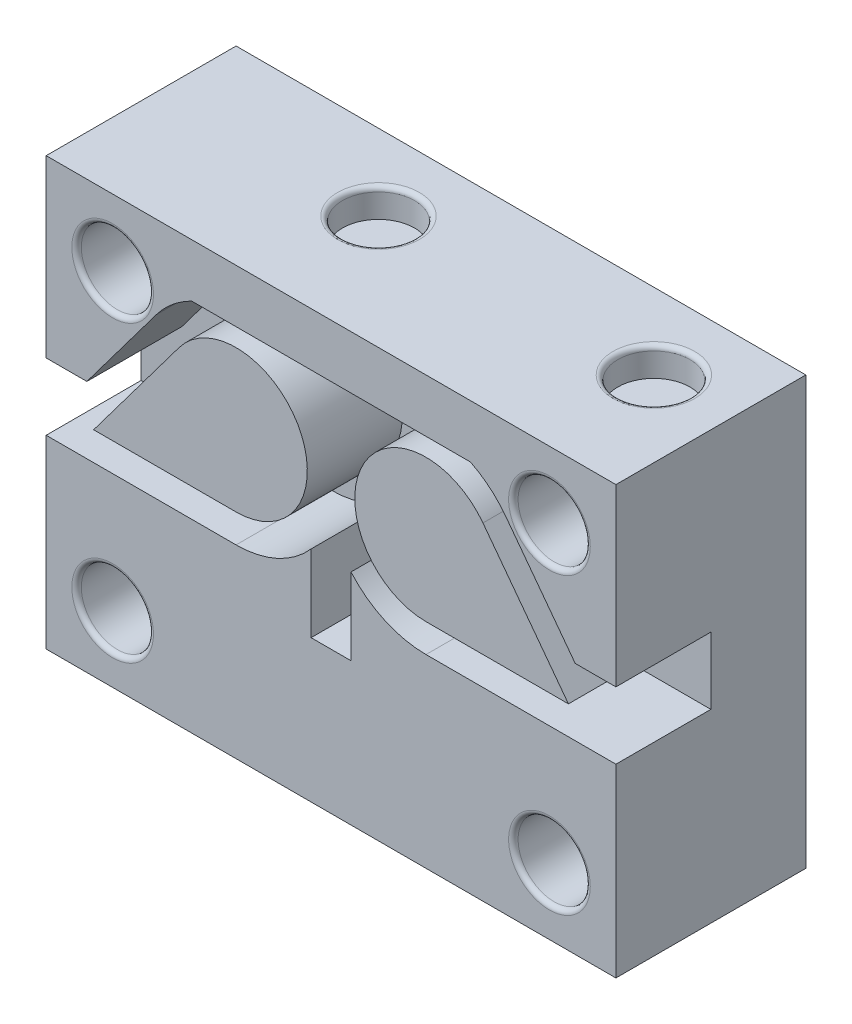
from build123d import *

# Parameters (mm, degrees)
BOSS_EXTRUDE19_DEPTH   = 20
BOSS_EXTRUDE19_2_DEPTH = 20
BOSS_EXTRUDE19_3_DEPTH = 20
BOSS_EXTRUDE19_4_DEPTH = 20
BOSS_EXTRUDE20_DEPTH   = 10
SKETCH3_R              = 3.8
CUT_EXTRUDE1_DEPTH     = 95.901264481
FILLET1_R              = 0.5
SKETCH4_R              = 3.8
CUT_EXTRUDE2_DEPTH     = 3
FILLET3_R              = 0.5
SKETCH5_R              = 3.925
CUT_EXTRUDE3_DEPTH     = 3
FILLET4_R              = 0.5


with BuildPart() as part:
    # Sketch2 → Boss-Extrude19 (new body)
    with BuildSketch(Plane.XY):
        with BuildLine():
            Line((-90, -22.5), (-30, -22.5))
            Line((-30, -22.5), (-30, -3))
            Line((-30, -3), (-50, -3))
            ThreePointArc((-50, -3), (-54.336927393, -2.062481937), (-57.899388544, 0.582655088))
            Line((-57.899388544, 0.582655088), (-57.899388544, -7.512763105))
            Line((-57.899388544, -7.512763105), (-62.100327913, -7.512763105))
            Line((-62.100327913, -7.512763105), (-62.100611456, 0.582655088))
            ThreePointArc((-62.100611456, 0.582655088), (-65.663072607, -2.062481937), (-70, -3))
            Line((-70, -3), (-90, -3))
            Line((-90, -3), (-90, -22.5))
        make_face()
    extrude(amount=BOSS_EXTRUDE19_DEPTH)



with BuildPart() as body_2:
    # Sketch2 → Boss-Extrude19 2 (new body)
    with BuildSketch(Plane.XY):
        with BuildLine():
            Line((-34.285720667, 4.047627556), (-30, 4.047627556))
            Line((-30, 4.047627556), (-30, 22.5))
            Line((-30, 22.5), (-90, 22.5))
            Line((-90, 22.5), (-90, 4.047627556))
            Line((-90, 4.047627556), (-85.714279333, 4.047627556))
            Line((-85.714279333, 4.047627556), (-78.4, 13.8))
            ThreePointArc((-78.4, 13.8), (-76.720396487, 15.567606278), (-74.678379216, 16.900147228))
            Line((-74.678379216, 16.900147228), (-45.321620784, 16.900147228))
            ThreePointArc((-45.321620784, 16.900147228), (-43.279603513, 15.567606278), (-41.6, 13.8))
            Line((-41.6, 13.8), (-34.285720667, 4.047627556))
        make_face()
    extrude(amount=BOSS_EXTRUDE19_2_DEPTH)


with BuildPart() as body_3:
    # Sketch2 → Boss-Extrude19 3 (new body)
    with BuildSketch(Plane.XY):
        with BuildLine():
            Line((-85, 0), (-70, 0))
            ThreePointArc((-70, 0), (-63.291796068, 10.854101966), (-76, 12))
            Line((-76, 12), (-85, 0))
        make_face()
    extrude(amount=BOSS_EXTRUDE19_3_DEPTH)


with BuildPart() as body_4:
    # Sketch2 → Boss-Extrude19 4 (new body)
    with BuildSketch(Plane.XY):
        with BuildLine():
            Line((-50, 0), (-35, 0))
            Line((-35, 0), (-44, 12))
            ThreePointArc((-44, 12), (-56.708203932, 10.854101966), (-50, 0))
        make_face()
    extrude(amount=BOSS_EXTRUDE19_4_DEPTH)


with BuildPart() as part_1:
    add(part.part)

    add(body_2.part)  # Boss-Extrude20 merges body 2

    add(body_3.part)  # Boss-Extrude20 merges body 3

    add(body_4.part)  # Boss-Extrude20 merges body 4
    # Sketch2_27 → Boss-Extrude20 (add)
    with BuildSketch(Plane.XY):
        with BuildLine():
            Line((-50, -3), (-30, -3))
            Line((-30, -3), (-30, 4.047627556))
            Line((-30, 4.047627556), (-34.285720667, 4.047627556))
            Line((-34.285720667, 4.047627556), (-41.6, 13.8))
            ThreePointArc((-41.6, 13.8), (-43.279603513, 15.567606278), (-45.321620784, 16.900147228))
            Line((-45.321620784, 16.900147228), (-74.678379216, 16.900147228))
            ThreePointArc((-74.678379216, 16.900147228), (-76.720396487, 15.567606278), (-78.4, 13.8))
            Line((-78.4, 13.8), (-85.714279333, 4.047627556))
            Line((-85.714279333, 4.047627556), (-90, 4.047627556))
            Line((-90, 4.047627556), (-90, -3))
            Line((-90, -3), (-70, -3))
            ThreePointArc((-70, -3), (-65.663072607, -2.062481937), (-62.100611456, 0.582655088))
            Line((-62.100611456, 0.582655088), (-62.100327913, -7.512763105))
            Line((-62.100327913, -7.512763105), (-57.899388544, -7.512763105))
            Line((-57.899388544, -7.512763105), (-57.899388544, -3))
            Line((-57.899388544, -3), (-57.899388544, 0.582655088))
            ThreePointArc((-57.899388544, 0.582655088), (-54.336927393, -2.062481937), (-50, -3))
        make_face()
        with BuildLine():
            ThreePointArc((-62.5, 7.5), (-64.696699141, 2.196699141), (-70, 0))
            Line((-70, 0), (-85, 0))
            Line((-85, 0), (-76, 12))
            ThreePointArc((-76, 12), (-67.628291755, 14.615124735), (-62.5, 7.5))
        make_face(mode=Mode.SUBTRACT)
        with BuildLine():
            Line((-44, 12), (-35, 0))
            Line((-35, 0), (-50, 0))
            ThreePointArc((-50, 0), (-56.708203932, 10.854101966), (-44, 12))
        make_face(mode=Mode.SUBTRACT)
    extrude(amount=BOSS_EXTRUDE20_DEPTH)

    # Sketch3 → Cut-Extrude1 (cut, through all)
    with BuildSketch(Plane.XY.offset(20)):
        with Locations((-83, 15.5)):
            Circle(SKETCH3_R)
        with Locations((-37, 15.5)):
            Circle(SKETCH3_R)
        with Locations((-37, -15.5)):
            Circle(SKETCH3_R)
        with Locations((-83, -15.5)):
            Circle(SKETCH3_R)
    extrude(amount=-CUT_EXTRUDE1_DEPTH, mode=Mode.SUBTRACT)

    # Fillet1
    fillet1_edges = [part_1.edges().sort_by_distance(p)[0] for p in [
        (-86.8, -15.5, 0),
        (-86.8, 15.5, 0),
        (-40.8, -15.5, 0),
        (-40.8, 15.5, 0),
        (-86.8, -15.5, 20),
        (-40.8, -15.5, 20),
        (-40.8, 15.5, 20),
        (-86.8, 15.5, 20),
    ]]
    fillet(fillet1_edges, radius=FILLET1_R)

    # Sketch4 → Cut-Extrude2 (cut)
    with BuildSketch(Plane(origin=(0, 22.5, 0), x_dir=(1, 0, 0), z_dir=(0, 1, 0))):
        with Locations((-38, -8)):
            Circle(SKETCH4_R)
        with Locations((-67, -8)):
            Circle(SKETCH4_R)
    extrude(amount=-CUT_EXTRUDE2_DEPTH, mode=Mode.SUBTRACT)

    # Fillet3
    fillet3_edges = [part_1.edges().sort_by_distance(p)[0] for p in [
        (-41.8, 22.5, 8),
        (-70.8, 22.5, 8),
    ]]
    fillet(fillet3_edges, radius=FILLET3_R)

    # Sketch5 → Cut-Extrude3 (cut)
    with BuildSketch(Plane.XZ.offset(22.5)):
        with Locations((-75, 9)):
            Circle(SKETCH5_R)
        with Locations((-45, 9)):
            Circle(SKETCH5_R)
    extrude(amount=-CUT_EXTRUDE3_DEPTH, mode=Mode.SUBTRACT)

    # Fillet4
    fillet4_edges = [part_1.edges().sort_by_distance(p)[0] for p in [
        (-48.925, -22.5, 9),
        (-78.925, -22.5, 9),
    ]]
    fillet(fillet4_edges, radius=FILLET4_R)


solid = part_1.part
